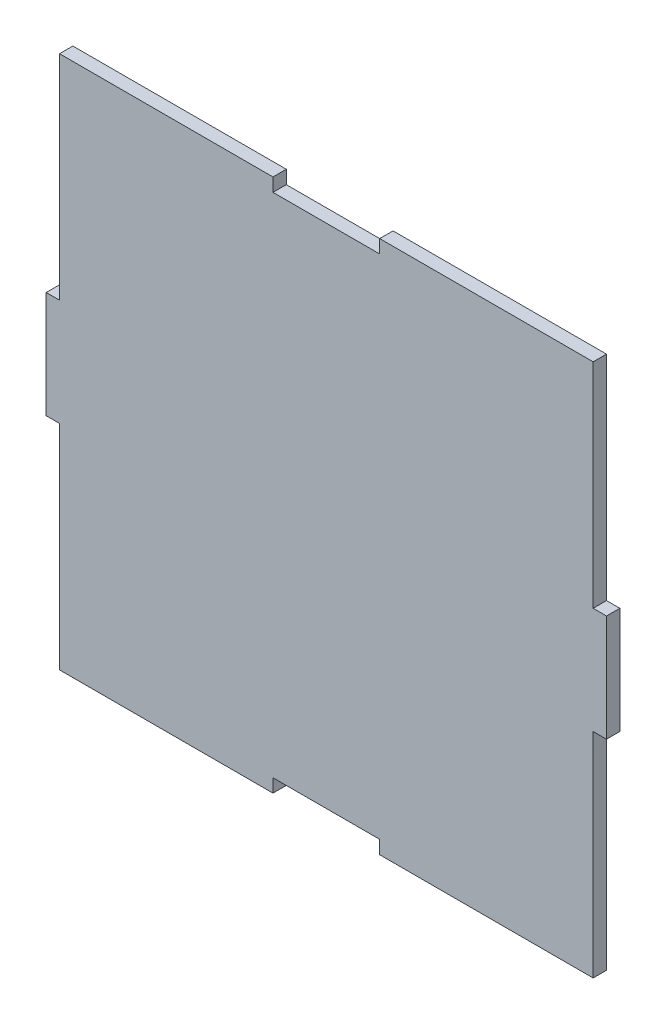
from build123d import *

# Parameters (mm, degrees)
SALIENTE_EXTRUIR1_DEPTH = 5


with BuildPart() as part:
    # Croquis1 → Saliente-Extruir1 (new body)
    with BuildSketch(Plane.XY):
        Polygon((-100, -100), (-100, -20), (-105, -20), (-105, 20), (-100, 20), (-100, 100), (-20, 100), (-20, 95), (20, 95), (20, 100), (100, 100), (100, 20), (105, 20), (105, -20), (100, -20), (100, -100), (20, -100), (20, -95), (-20, -95), (-20, -100), align=None)
    extrude(amount=SALIENTE_EXTRUIR1_DEPTH)


solid = part.part
